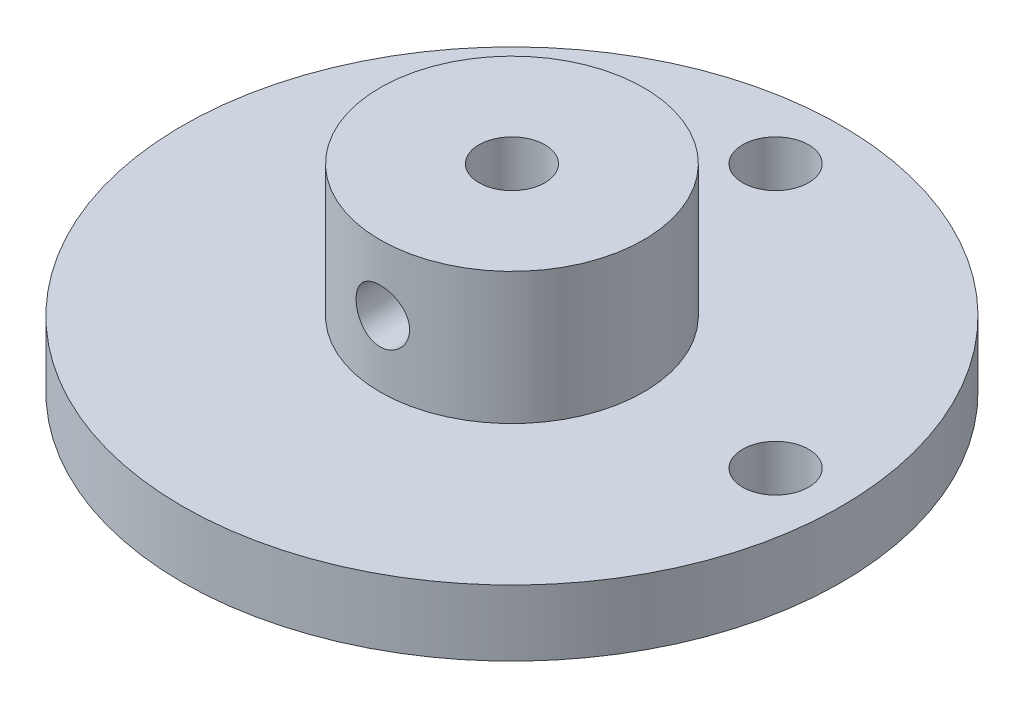
from build123d import *

# Parameters (mm, degrees)
SKETCH1_R           = 15.875
SKETCH1_R_2         = 1.5875
BOSS_EXTRUDE1_DEPTH = 3.175
SKETCH2_R           = 6.35
BOSS_EXTRUDE2_DEPTH = 6.35
SKETCH3_R           = 1.5875
CUT_EXTRUDE1_DEPTH  = 10.525


with BuildPart() as part:
    # Sketch1 → Boss-Extrude1 (new body)
    with BuildSketch(Plane(origin=(0, 0, 0), x_dir=(1, 0, 0), z_dir=(0, 1, 0))):
        Circle(SKETCH1_R)
        with Locations((0, 12.7)):
            Circle(SKETCH1_R_2, mode=Mode.SUBTRACT)
        with Locations((12.7, 0)):
            Circle(SKETCH1_R_2, mode=Mode.SUBTRACT)
    extrude(amount=BOSS_EXTRUDE1_DEPTH)

    # Sketch2 → Boss-Extrude2 (add)
    with BuildSketch(Plane(origin=(0, 3.175, 0), x_dir=(1, 0, 0), z_dir=(0, 1, 0))):
        Circle(SKETCH2_R)
    extrude(amount=BOSS_EXTRUDE2_DEPTH)

    # Sketch3 → Cut-Extrude1 (cut, through all)
    with BuildSketch(Plane(origin=(0, 9.525, 0), x_dir=(1, 0, 0), z_dir=(0, 1, 0))):
        Circle(SKETCH3_R)
    extrude(amount=-CUT_EXTRUDE1_DEPTH, mode=Mode.SUBTRACT)

    # Sketch5 → #38 (0.1015) Diameter Hole1 (revolve, cut)
    with BuildSketch(Plane(origin=(0, 6.35, 0), x_dir=(0, 1, 0), z_dir=(1, 0, 0))):
        Polygon((0, 0), (0, 26.174539381), (1.28905, 25.4), (1.28905, 0), align=None)
    revolve(axis=Axis((0, 6.35, -6.35), (0, 0, 1)), mode=Mode.SUBTRACT)


solid = part.part
